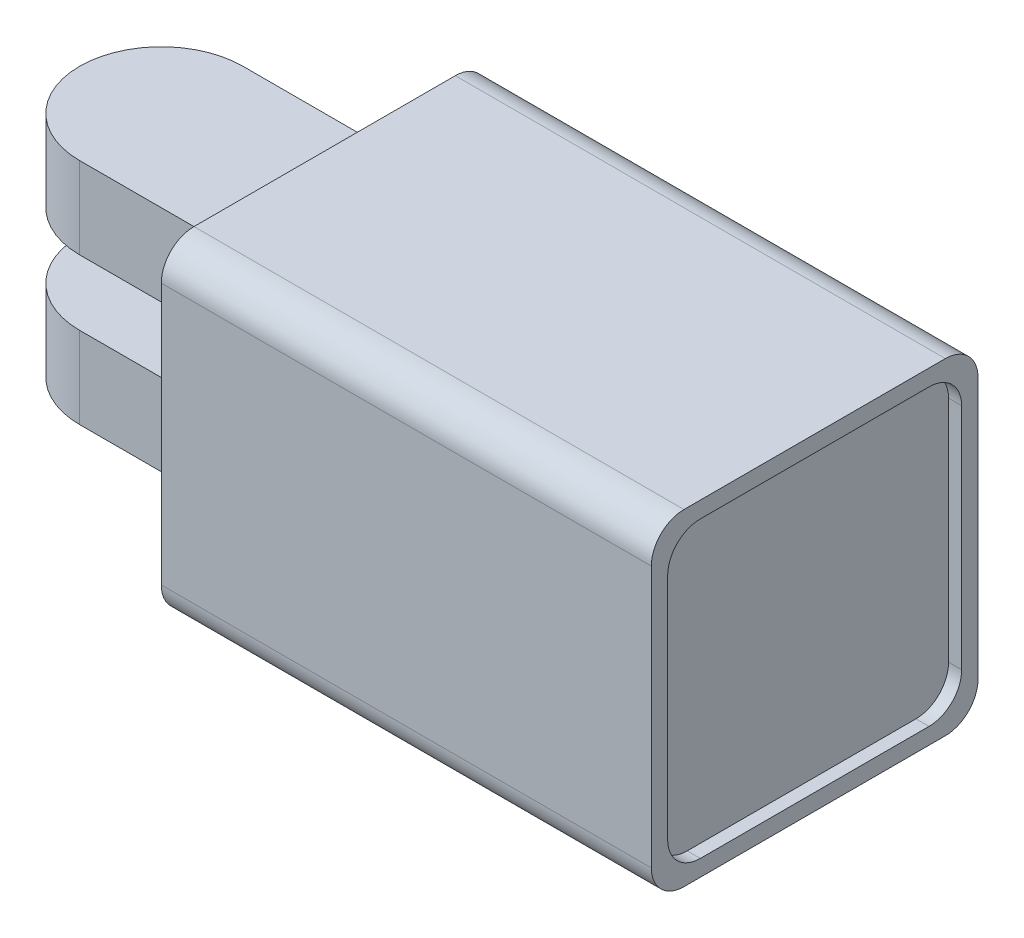
from build123d import *

# Parameters (mm, degrees)
BOSS_EXTRUDE1_DEPTH = 14
SKETCH3_W           = 20
SKETCH3_H           = 20
BOSS_EXTRUDE2_DEPTH = 30
SKETCH4_W           = 18
SKETCH4_H           = 18
CUT_EXTRUDE1_DEPTH  = 3
FILLET2_R           = 2
FILLET3_R           = 2
CUT_EXTRUDE2_DEPTH  = 0.5
BOSS_EXTRUDE3_DEPTH = 0.2
SKETCH8_W           = 10
SKETCH8_H           = 4
CUT_EXTRUDE4_DEPTH  = 20


with BuildPart() as part:
    # Sketch1 → Boss-Extrude1 (new body)
    with BuildSketch(Plane(origin=(0, 0, 0), x_dir=(1, 0, 0), z_dir=(0, 1, 0))):
        with BuildLine():
            Line((0, 5), (10, 5))
            Line((10, 5), (10, -5))
            Line((10, -5), (0, -5))
            ThreePointArc((0, -5), (-5, 0), (0, 5))
        make_face()
    extrude(amount=BOSS_EXTRUDE1_DEPTH)

    # Sketch3 → Boss-Extrude2 (add)
    with BuildSketch(Plane(origin=(10, 0, 0), x_dir=(0, 0, -1), z_dir=(1, 0, 0))):
        with Locations((0, 7)):
            Rectangle(SKETCH3_W, SKETCH3_H)
    extrude(amount=BOSS_EXTRUDE2_DEPTH)

    # Sketch4 → Cut-Extrude1 (cut)
    with BuildSketch(Plane(origin=(40, 0, 0), x_dir=(0, 0, -1), z_dir=(1, 0, 0))):
        with Locations((0, 7)):
            Rectangle(SKETCH4_W, SKETCH4_H)
    extrude(amount=-CUT_EXTRUDE1_DEPTH, mode=Mode.SUBTRACT)

    # Fillet2
    fillet2_edges = [part.edges().sort_by_distance(p)[0] for p in [
        (25, -3, -10),
        (25, 17, -10),
        (25, 17, 10),
        (25, -3, 10),
    ]]
    fillet(fillet2_edges, radius=FILLET2_R)

    # Fillet3
    fillet3_edges = [part.edges().sort_by_distance(p)[0] for p in [
        (38.5, 16, -9),
        (38.5, -2, -9),
        (38.5, -2, 9),
        (38.5, 16, 9),
    ]]
    fillet(fillet3_edges, radius=FILLET3_R)

    # Sketch5 → Cut-Extrude2 (cut)
    with BuildSketch(Plane(origin=(37, 0, 0), x_dir=(0, 0, -1), z_dir=(1, 0, 0))):
        with BuildLine():
            ThreePointArc((4, 7), (1.530733729, 10.69551813), (-2.828427125, 9.828427125))
            Line((-2.828427125, 9.828427125), (2.828427125, 4.171572875))
            ThreePointArc((2.828427125, 4.171572875), (3.69551813, 5.469266271), (4, 7))
        make_face()
        with BuildLine():
            Line((2.828427125, 4.171572875), (-2.828427125, 9.828427125))
            ThreePointArc((-2.828427125, 9.828427125), (-2.828427125, 4.171572875), (2.828427125, 4.171572875))
        make_face()
    extrude(amount=-CUT_EXTRUDE2_DEPTH, mode=Mode.SUBTRACT)

    # Sketch6 → Boss-Extrude3 (add)
    with BuildSketch(Plane(origin=(39, 0, 0), x_dir=(0, 0, -1), z_dir=(1, 0, 0))):
        with BuildLine():
            Line((-7, 16), (7, 16))
            ThreePointArc((7, 16), (8.414213562, 15.414213562), (9, 14))
            Line((9, 14), (9, 0))
            ThreePointArc((9, 0), (8.414213562, -1.414213562), (7, -2))
            Line((7, -2), (-7, -2))
            ThreePointArc((-7, -2), (-8.414213562, -1.414213562), (-9, 0))
            Line((-9, 0), (-9, 14))
            ThreePointArc((-9, 14), (-8.414213562, 15.414213562), (-7, 16))
        make_face()
    extrude(amount=BOSS_EXTRUDE3_DEPTH)

    # Sketch8 → Cut-Extrude4 (cut)
    with BuildSketch(Plane(origin=(0, 0, -5), x_dir=(-1, 0, 0), z_dir=(0, 0, -1))):
        with Locations((0, 7)):
            Rectangle(SKETCH8_W, SKETCH8_H)
    extrude(amount=-CUT_EXTRUDE4_DEPTH, mode=Mode.SUBTRACT)


solid = part.part
